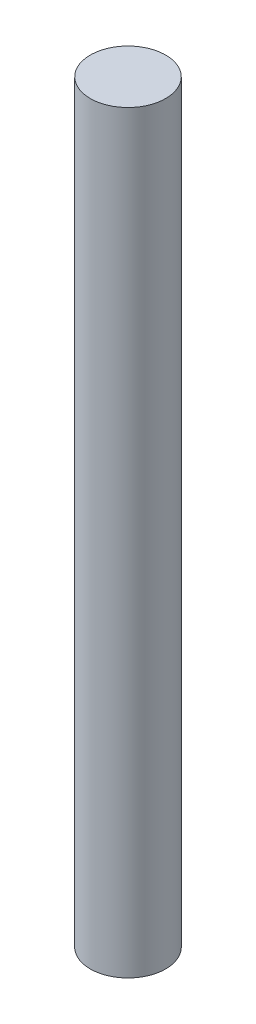
from build123d import *

# Parameters (mm, degrees)
SKETCH_1_R      = 4
EXTRUDE_1_DEPTH = 80


with BuildPart() as part:
    # 草图1 → 凸台-拉伸1 (new body)
    with BuildSketch(Plane(origin=(0, 0, 0), x_dir=(1, 0, 0), z_dir=(0, 1, 0))):
        Circle(SKETCH_1_R)
    extrude(amount=EXTRUDE_1_DEPTH)


solid = part.part
